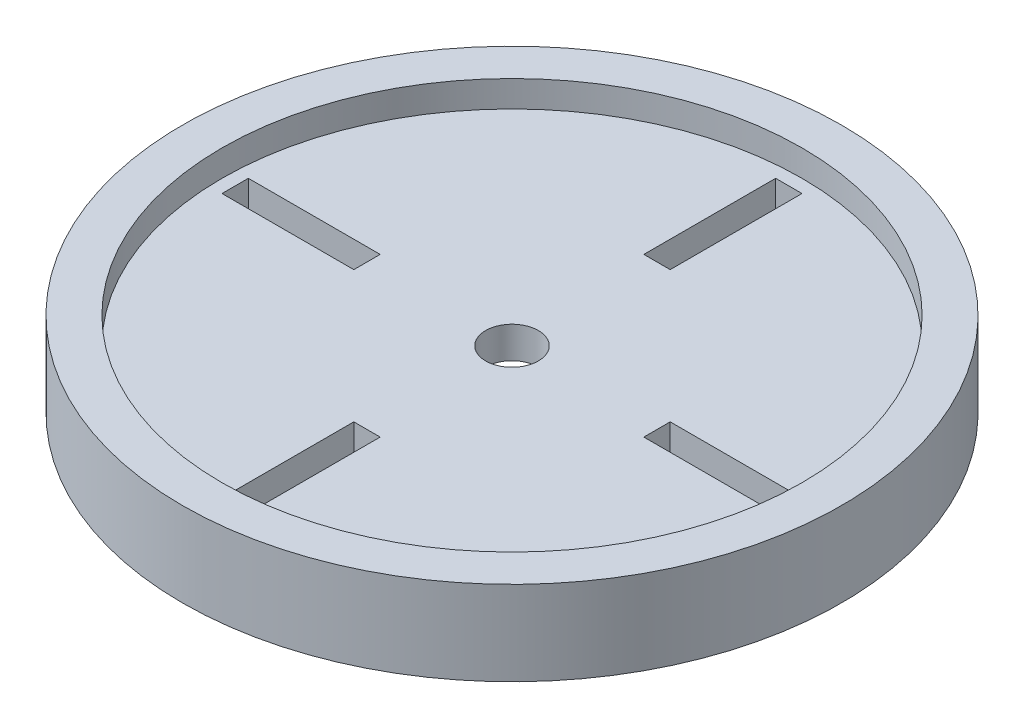
from build123d import *

# Parameters (mm, degrees)
BOSS_EXTRUDE1_DEPTH      = 8
BOSS_EXTRUDE1_DEPTH_BACK = 8
SKETCH1_R                = 62.5
SKETCH2_R                = 55
CUT_EXTRUDE1_DEPTH       = 5
CUT_EXTRUDE2_START       = -5
SKETCH3_R                = 55
CUT_EXTRUDE2_DEPTH       = 5
SKETCH4_R                = 5
CUT_EXTRUDE3_DEPTH       = 90.070197036
SKETCH5_W                = 5
SKETCH5_H                = 25
CUT_EXTRUDE4_DEPTH       = 90.070197036
CIRPATTERN1_COUNT        = 4


with BuildPart() as part:
    # Sketch1 → Boss-Extrude1 (new, two sides: drawn at the far end of the back side and taken through both)
    with BuildSketch(Plane(origin=(0, 0, 0), x_dir=(1, 0, 0), z_dir=(0, 1, 0)).offset(-BOSS_EXTRUDE1_DEPTH_BACK)):
        Circle(SKETCH1_R)
    extrude(amount=BOSS_EXTRUDE1_DEPTH + BOSS_EXTRUDE1_DEPTH_BACK)

    # Sketch2 → Cut-Extrude1 (cut)
    with BuildSketch(Plane(origin=(0, 8, 0), x_dir=(1, 0, 0), z_dir=(0, 1, 0))):
        Circle(SKETCH2_R)
    extrude(amount=-CUT_EXTRUDE1_DEPTH, mode=Mode.SUBTRACT)

    # Sketch3 → Cut-Extrude2 (cut)
    with BuildSketch(Plane.XZ.offset(8).offset(CUT_EXTRUDE2_START)):
        Circle(SKETCH3_R)
    extrude(amount=CUT_EXTRUDE2_DEPTH, mode=Mode.SUBTRACT)

    # Sketch4 → Cut-Extrude3 (cut, through all)
    with BuildSketch(Plane.XZ.offset(3)):
        Circle(SKETCH4_R)
    extrude(amount=-CUT_EXTRUDE3_DEPTH, mode=Mode.SUBTRACT)

    # Sketch5 → Cut-Extrude4 (cut, through all)
    with BuildSketch(Plane.XZ.offset(3)):
        with Locations((0, 40)):
            Rectangle(SKETCH5_W, SKETCH5_H)
    cut_extrude4 = extrude(amount=-CUT_EXTRUDE4_DEPTH, mode=Mode.SUBTRACT)

    # CirPattern1: Cut-Extrude4 ×4 about axis
    cirpattern1_axis = Axis((0, -8, 0), (0, 1, 0))
    for i in range(1, CIRPATTERN1_COUNT):
        add(cut_extrude4.rotate(cirpattern1_axis, i * 360 / CIRPATTERN1_COUNT), mode=Mode.SUBTRACT)


solid = part.part
